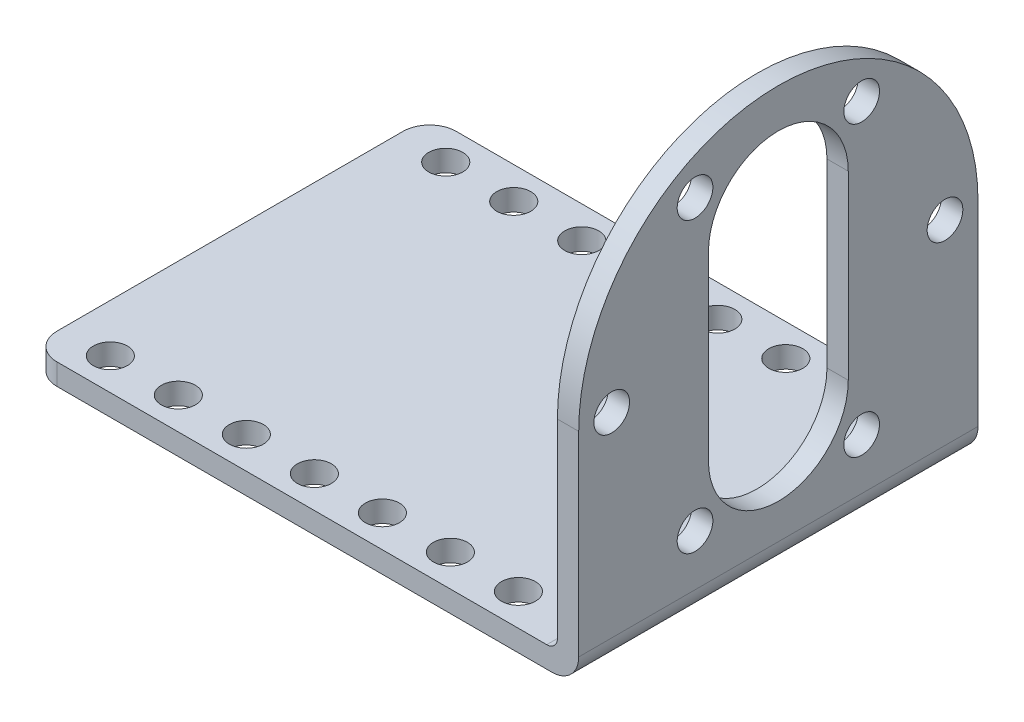
from build123d import *

# Parameters (mm, degrees)
SKETCH1_R           = 1.675
BOSS_EXTRUDE1_DEPTH = 2
SKETCH2_W           = 49.5
SKETCH2_H           = 37.5
SKETCH2_R           = 1.6
BOSS_EXTRUDE2_DEPTH = 2
FILLET1_R           = 2.5
FILLET2_R           = 1


with BuildPart() as part:
    # Sketch1 → Boss-Extrude1 (new body)
    with BuildSketch(Plane(origin=(0, 0, 0), x_dir=(0, 0, -1), z_dir=(1, 0, 0))):
        with BuildLine():
            Line((-18.75, 0), (18.75, 0))
            Line((18.75, 0), (18.75, 20.85))
            ThreePointArc((18.75, 20.85), (0, 39.6), (-18.75, 20.85))
            Line((-18.75, 20.85), (-18.75, 0))
        make_face()
        with Locations((-7.825, 7.296702431)):
            Circle(SKETCH1_R, mode=Mode.SUBTRACT)
        with Locations((7.825, 7.296702431)):
            Circle(SKETCH1_R, mode=Mode.SUBTRACT)
        with Locations((-15.65, 20.85)):
            Circle(SKETCH1_R, mode=Mode.SUBTRACT)
        with Locations((-7.825, 34.403297569)):
            Circle(SKETCH1_R, mode=Mode.SUBTRACT)
        with BuildLine():
            Line((-6.565, 12.35), (-6.565, 29.35))
            ThreePointArc((-6.565, 29.35), (0, 35.915), (6.565, 29.35))
            Line((6.565, 29.35), (6.565, 12.35))
            ThreePointArc((6.565, 12.35), (0, 5.785), (-6.565, 12.35))
        make_face(mode=Mode.SUBTRACT)
        with Locations((15.65, 20.85)):
            Circle(SKETCH1_R, mode=Mode.SUBTRACT)
        with Locations((7.825, 34.403297569)):
            Circle(SKETCH1_R, mode=Mode.SUBTRACT)
    extrude(amount=BOSS_EXTRUDE1_DEPTH)

    # Sketch2 → Boss-Extrude2 (add)
    with BuildSketch(Plane(origin=(0, 0, 0), x_dir=(1, 0, 0), z_dir=(0, 1, 0))):
        with Locations((-24.75, 0)):
            Rectangle(SKETCH2_W, SKETCH2_H)
        with Locations((-44.9875, 15.75)):
            Circle(SKETCH2_R, mode=Mode.SUBTRACT)
        with Locations((-38.6, 15.75)):
            Circle(SKETCH2_R, mode=Mode.SUBTRACT)
        with Locations((-32.2125, 15.75)):
            Circle(SKETCH2_R, mode=Mode.SUBTRACT)
        with Locations((-25.825, 15.75)):
            Circle(SKETCH2_R, mode=Mode.SUBTRACT)
        with Locations((-19.4375, 15.75)):
            Circle(SKETCH2_R, mode=Mode.SUBTRACT)
        with Locations((-13.05, 15.75)):
            Circle(SKETCH2_R, mode=Mode.SUBTRACT)
        with Locations((-6.6625, 15.75)):
            Circle(SKETCH2_R, mode=Mode.SUBTRACT)
        with Locations((-6.6625, -15.75)):
            Circle(SKETCH2_R, mode=Mode.SUBTRACT)
        with Locations((-13.05, -15.75)):
            Circle(SKETCH2_R, mode=Mode.SUBTRACT)
        with Locations((-19.4375, -15.75)):
            Circle(SKETCH2_R, mode=Mode.SUBTRACT)
        with Locations((-44.9875, -15.75)):
            Circle(SKETCH2_R, mode=Mode.SUBTRACT)
        with Locations((-38.6, -15.75)):
            Circle(SKETCH2_R, mode=Mode.SUBTRACT)
        with Locations((-32.2125, -15.75)):
            Circle(SKETCH2_R, mode=Mode.SUBTRACT)
        with Locations((-25.825, -15.75)):
            Circle(SKETCH2_R, mode=Mode.SUBTRACT)
    extrude(amount=BOSS_EXTRUDE2_DEPTH)

    # Fillet1
    fillet1_edges = [part.edges().sort_by_distance(p)[0] for p in [
        (-49.5, 1, 18.75),
        (-49.5, 1, -18.75),
        (2, 0, 0),
    ]]
    fillet(fillet1_edges, radius=FILLET1_R)

    # Fillet2
    fillet2_edges = [part.edges().sort_by_distance(p)[0] for p in [
        (0, 2, 0),
    ]]
    fillet(fillet2_edges, radius=FILLET2_R)


solid = part.part
